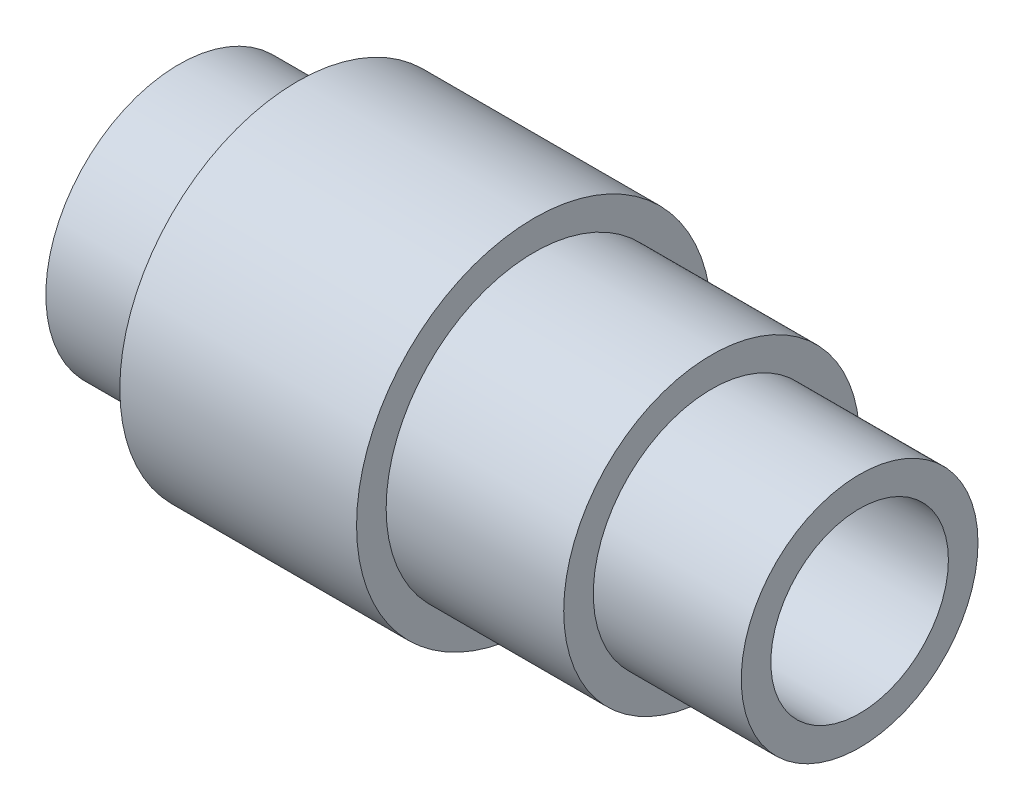
from build123d import *

# Parameters (mm, degrees)
SKETCH1_R           = 22.5
BOSS_EXTRUDE1_DEPTH = 20
SKETCH2_R           = 30
BOSS_EXTRUDE2_DEPTH = 40
SKETCH3_R           = 25
BOSS_EXTRUDE3_DEPTH = 30
SKETCH4_R           = 20
BOSS_EXTRUDE4_DEPTH = 25
SKETCH5_R           = 15
CUT_EXTRUDE1_DEPTH  = 116


with BuildPart() as part:
    # Sketch1 → Boss-Extrude1 (new body)
    with BuildSketch(Plane(origin=(0, 0, 0), x_dir=(0, 0, -1), z_dir=(1, 0, 0))):
        Circle(SKETCH1_R)
    extrude(amount=BOSS_EXTRUDE1_DEPTH)

    # Sketch2 → Boss-Extrude2 (add)
    with BuildSketch(Plane(origin=(20, 0, 0), x_dir=(0, 0, -1), z_dir=(1, 0, 0))):
        Circle(SKETCH2_R)
    extrude(amount=BOSS_EXTRUDE2_DEPTH)

    # Sketch3 → Boss-Extrude3 (add)
    with BuildSketch(Plane(origin=(60, 0, 0), x_dir=(0, 0, -1), z_dir=(1, 0, 0))):
        Circle(SKETCH3_R)
    extrude(amount=BOSS_EXTRUDE3_DEPTH)

    # Sketch4 → Boss-Extrude4 (add)
    with BuildSketch(Plane(origin=(90, 0, 0), x_dir=(0, 0, -1), z_dir=(1, 0, 0))):
        Circle(SKETCH4_R)
    extrude(amount=BOSS_EXTRUDE4_DEPTH)

    # Sketch5 → Cut-Extrude1 (cut, through all)
    with BuildSketch(Plane(origin=(115, 0, 0), x_dir=(0, 0, -1), z_dir=(1, 0, 0))):
        Circle(SKETCH5_R)
    extrude(amount=-CUT_EXTRUDE1_DEPTH, mode=Mode.SUBTRACT)


solid = part.part
